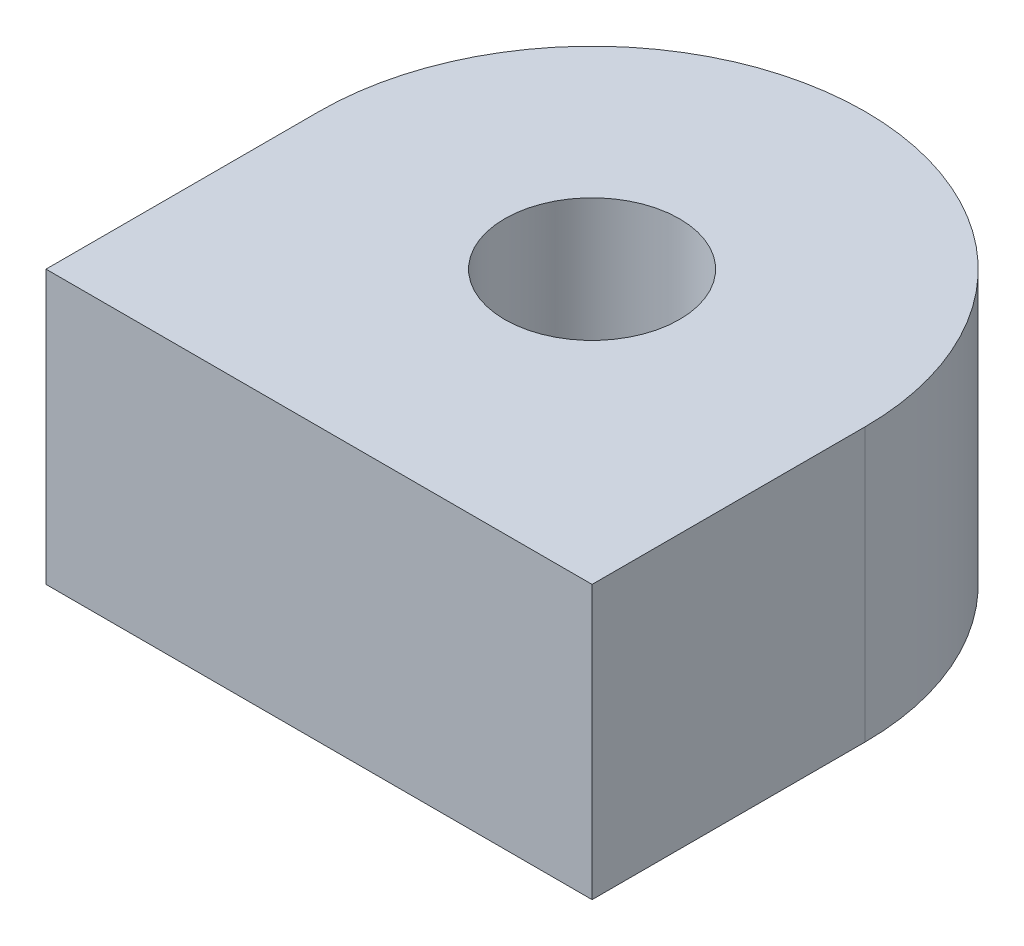
from build123d import *

# Parameters (mm, degrees)
SKETCH1_R           = 3.2
BOSS_EXTRUDE1_DEPTH = 10


with BuildPart() as part:
    # Sketch1 → Boss-Extrude1 (new body)
    with BuildSketch(Plane(origin=(0, 0, 0), x_dir=(1, 0, 0), z_dir=(0, 1, 0))):
        with BuildLine():
            Line((0, 0), (0, -10))
            Line((0, -10), (20, -10))
            Line((20, -10), (20, 0))
            ThreePointArc((20, 0), (10, 10), (0, 0))
        make_face()
        with Locations((10, 0)):
            Circle(SKETCH1_R, mode=Mode.SUBTRACT)
    extrude(amount=-BOSS_EXTRUDE1_DEPTH)


solid = part.part
